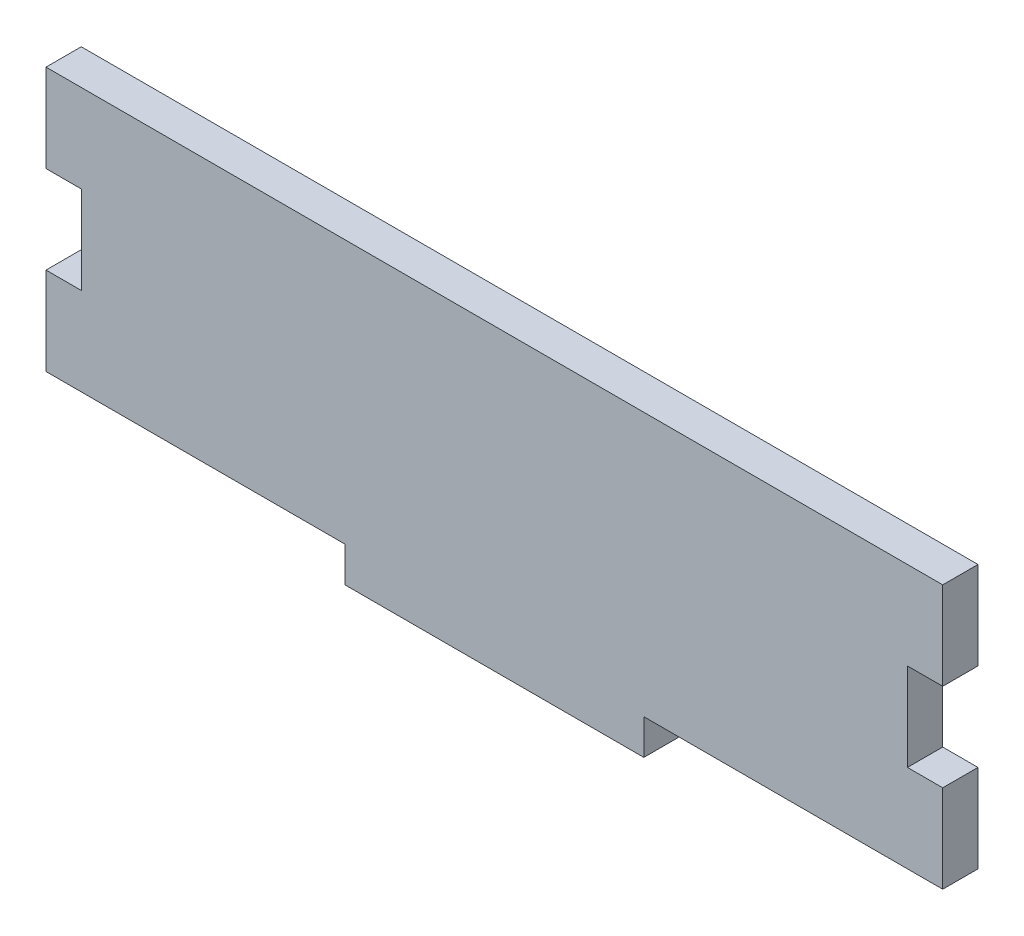
from build123d import *

# Parameters (mm, degrees)
BOSS_EXTRUDE1_DEPTH = 2.9972


with BuildPart() as part:
    # Sketch1 → Boss-Extrude1 (new body)
    with BuildSketch(Plane.XY):
        Polygon((32.049205529, 27.331164833), (62.529205529, 27.331164833), (62.529205529, 19.863564833), (59.532005529, 19.863564833), (59.532005529, 12.395964833), (62.529205529, 12.395964833), (62.529205529, 4.928364833), (37.129205529, 4.928364833), (37.129205529, 1.931164833), (11.729205529, 1.931164833), (11.729205529, 4.928364833), (-13.670794471, 4.928364833), (-13.670794471, 12.395964833), (-10.673594471, 12.395964833), (-10.673594471, 19.863564833), (-13.670794471, 19.863564833), (-13.670794471, 27.331164833), (16.809205529, 27.331164833), align=None)
    extrude(amount=BOSS_EXTRUDE1_DEPTH)


solid = part.part
